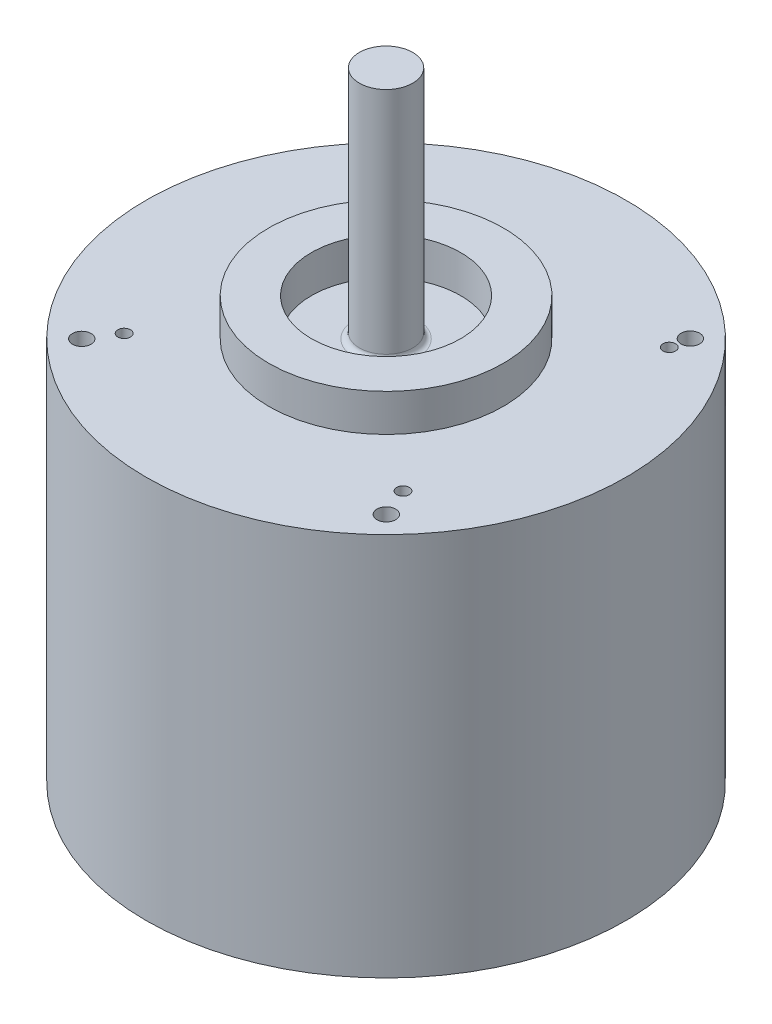
from build123d import *

# Parameters (mm, degrees)
SKETCH1_R                    = 22.5
BOSS_EXTRUDE1_DEPTH          = 36
SKETCH2_R                    = 11
BOSS_EXTRUDE2_DEPTH          = 3.5
SKETCH5_R                    = 7
CUT_EXTRUDE1_DEPTH           = 3.5
SKETCH6_R                    = 2.5
BOSS_EXTRUDE3_DEPTH          = 22
FILLET1_R                    = 0.5
M2_2X0_45_TAPPED_HOLE1_D     = 1.75
M2_2X0_45_TAPPED_HOLE1_DEPTH = 5.75
M2_2X0_45_TAPPED_HOLE1_TIP   = 0.525753042
SKETCH21_R                   = 2.490055496
BOSS_EXTRUDE6_DEPTH          = 7
F_0_80_TAPPED_HOLE3_D        = 1.19126
F_0_80_TAPPED_HOLE3_DEPTH    = 10
F_0_80_TAPPED_HOLE3_TIP      = 0.357890611
SKETCH17_R                   = 2.5
BOSS_EXTRUDE5_DEPTH          = 6


with BuildPart() as part:
    # Sketch1 → Boss-Extrude1 (new body)
    with BuildSketch(Plane(origin=(0, 0, 0), x_dir=(1, 0, 0), z_dir=(0, 1, 0))):
        Circle(SKETCH1_R)
    extrude(amount=BOSS_EXTRUDE1_DEPTH)

    # Sketch2 → Boss-Extrude2 (add)
    with BuildSketch(Plane(origin=(0, 36, 0), x_dir=(1, 0, 0), z_dir=(0, 1, 0))):
        Circle(SKETCH2_R)
    extrude(amount=BOSS_EXTRUDE2_DEPTH)

    # Sketch5 → Cut-Extrude1 (cut)
    with BuildSketch(Plane(origin=(0, 39.5, 0), x_dir=(1, 0, 0), z_dir=(0, 1, 0))):
        Circle(SKETCH5_R)
    extrude(amount=-CUT_EXTRUDE1_DEPTH, mode=Mode.SUBTRACT)

    # Sketch6 → Boss-Extrude3 (add)
    with BuildSketch(Plane(origin=(0, 36, 0), x_dir=(1, 0, 0), z_dir=(0, 1, 0))):
        Circle(SKETCH6_R)
    extrude(amount=BOSS_EXTRUDE3_DEPTH)

    # Fillet1
    fillet1_edges = [part.edges().sort_by_distance(p)[0] for p in [
        (-2.5, 36, 0),
    ]]
    fillet(fillet1_edges, radius=FILLET1_R)

    # M2.2x0.45 Tapped Hole1
    with Locations(Plane(origin=(-14.276653016, 36, -14.253421631), x_dir=(0, 0, 1), z_dir=(0, 1, 0))):
        with Locations((0, 0), (-0.023231385, 28.530074647), (28.530074647, 0.023231385), (28.506843262, 28.553306032)):
            Hole(M2_2X0_45_TAPPED_HOLE1_D / 2, depth=M2_2X0_45_TAPPED_HOLE1_DEPTH)
            with Locations((0, 0, -(M2_2X0_45_TAPPED_HOLE1_DEPTH + M2_2X0_45_TAPPED_HOLE1_TIP / 2))):  # 118° drill point
                Cone(0, M2_2X0_45_TAPPED_HOLE1_D / 2, M2_2X0_45_TAPPED_HOLE1_TIP, mode=Mode.SUBTRACT)

    # Sketch21 → Boss-Extrude6 (add)
    with BuildSketch(Plane.XZ):
        with Locations((0, -11.5)):
            Circle(SKETCH21_R)
    extrude(amount=BOSS_EXTRUDE6_DEPTH)

    # #0-80 Tapped Hole3
    with Locations(Plane(origin=(-13.163543756, 36, -12.028755501), x_dir=(0, 0, 1), z_dir=(0, 1, 0))):
        with Locations((0, 0), (23.6035957, 26.327087512), (-0.544698362, 27.144135055), (23.875944881, 0.453915302)):
            Hole(F_0_80_TAPPED_HOLE3_D / 2, depth=F_0_80_TAPPED_HOLE3_DEPTH)
            with Locations((0, 0, -(F_0_80_TAPPED_HOLE3_DEPTH + F_0_80_TAPPED_HOLE3_TIP / 2))):  # 118° drill point
                Cone(0, F_0_80_TAPPED_HOLE3_D / 2, F_0_80_TAPPED_HOLE3_TIP, mode=Mode.SUBTRACT)

    # Sketch17 → Boss-Extrude5 (add)
    with BuildSketch(Plane(origin=(0, 0, 0), x_dir=(1, 0, 0), z_dir=(0, 1, 0))):
        with Locations((0, 11.5)):
            Circle(SKETCH17_R)
    extrude(amount=-BOSS_EXTRUDE5_DEPTH)


solid = part.part
